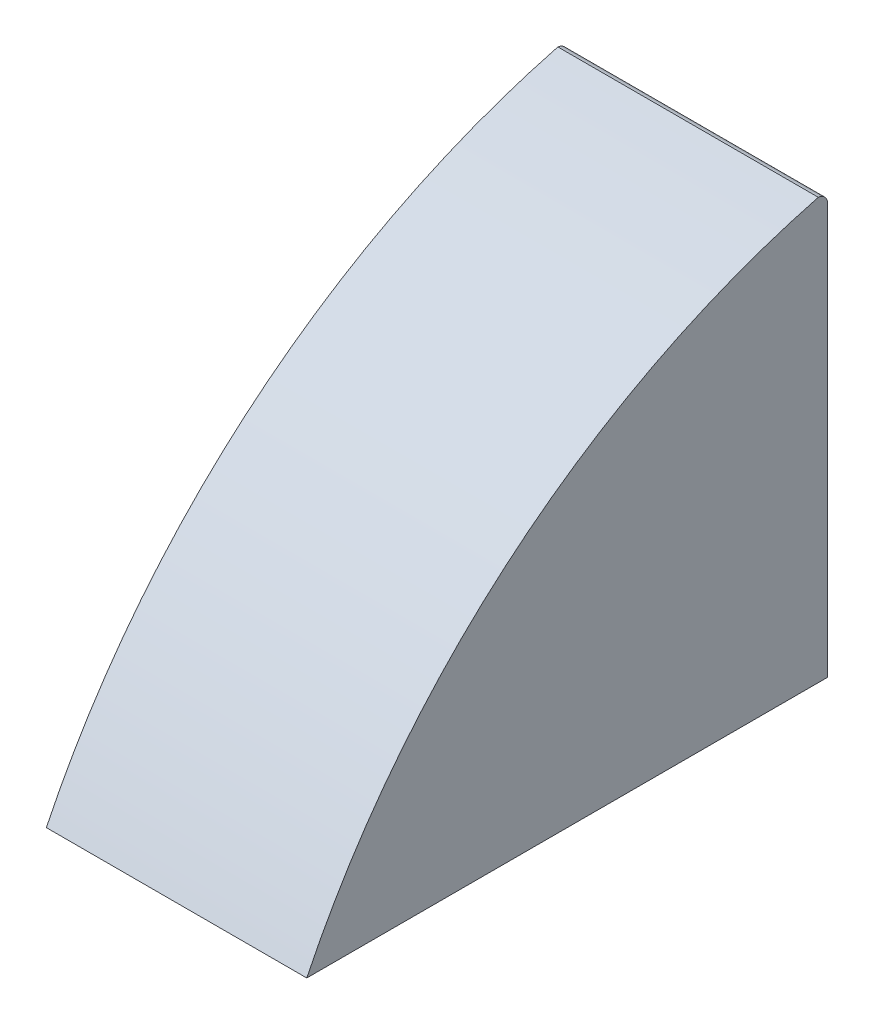
from build123d import *

# Parameters (mm, degrees)
BOSS_EXTRUDE1_DEPTH = 6.35


with BuildPart() as part:
    # Sketch1 → Boss-Extrude1 (new body)
    with BuildSketch(Plane(origin=(0, 0, 0), x_dir=(0, 0, -1), z_dir=(1, 0, 0))):
        with BuildLine():
            Line((-17.135859979, 4.940851666), (-4.435859979, 4.940851666))
            Line((-4.435859979, 4.940851666), (-4.435859979, 14.940851666))
            ThreePointArc((-4.435859979, 14.940851666), (-4.501465752, 15.10966745), (-4.66385013, 15.189880915))
            ThreePointArc((-4.66385013, 15.189880915), (-12.026637987, 11.436544721), (-17.135859979, 4.940851666))
        make_face()
    extrude(amount=BOSS_EXTRUDE1_DEPTH)


solid = part.part
